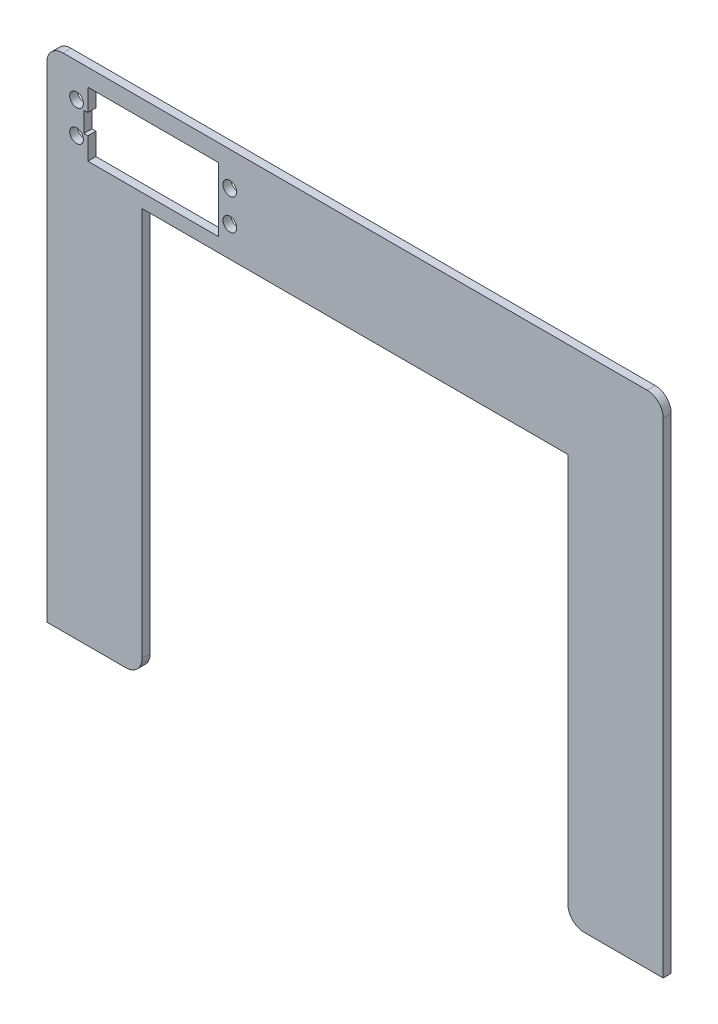
from build123d import *

# Parameters (mm, degrees)
BOSS_EXTRUDE1_DEPTH = 2.54
SKETCH2_R           = 2.159
CUT_EXTRUDE1_DEPTH  = 2.54
FILLET1_R           = 5.08
SKETCH3_W           = 2.54
SKETCH3_H           = 6.35
CUT_EXTRUDE4_DEPTH  = 3.54


with BuildPart() as part:
    # Sketch1 → Boss-Extrude1 (new body)
    with BuildSketch(Plane.XY):
        Polygon((67.0433, -78.881), (67.0433, 48.881), (-67.0433, 48.881), (-67.0433, -78.881), (-97.0433, -78.881), (-97.0433, 78.881), (97.0433, 78.881), (97.0433, -78.881), align=None)
    extrude(amount=BOSS_EXTRUDE1_DEPTH)

    # Sketch2 → Cut-Extrude1 (cut)
    with BuildSketch(Plane.XY.offset(2.54)):
        with Locations((-87.6643, 68.2485)):
            Circle(SKETCH2_R)
        with Locations((-87.6643, 58.4695)):
            Circle(SKETCH2_R)
        with Locations((-39.4043, 68.2485)):
            Circle(SKETCH2_R)
        with Locations((-39.4043, 58.4695)):
            Circle(SKETCH2_R)
        Polygon((-42.9603, 73.4555), (-84.1083, 73.4555), (-84.1083, 53.2625), (-42.9603, 53.2625), (-42.9603, 63.359), align=None)
    extrude(amount=-CUT_EXTRUDE1_DEPTH, mode=Mode.SUBTRACT)

    # Fillet1
    fillet1_edges = [part.edges().sort_by_distance(p)[0] for p in [
        (-97.0433, 78.881, 1.27),
        (97.0433, 78.881, 1.27),
        (67.0433, -78.881, 1.27),
        (-67.0433, -78.881, 1.27),
    ]]
    fillet(fillet1_edges, radius=FILLET1_R)

    # Sketch3 → Cut-Extrude4 (cut, through all)
    with BuildSketch(Plane.XY.offset(2.54)):
        with Locations((-84.1083, 63.359)):
            Rectangle(SKETCH3_W, SKETCH3_H)
    extrude(amount=-CUT_EXTRUDE4_DEPTH, mode=Mode.SUBTRACT)


solid = part.part
